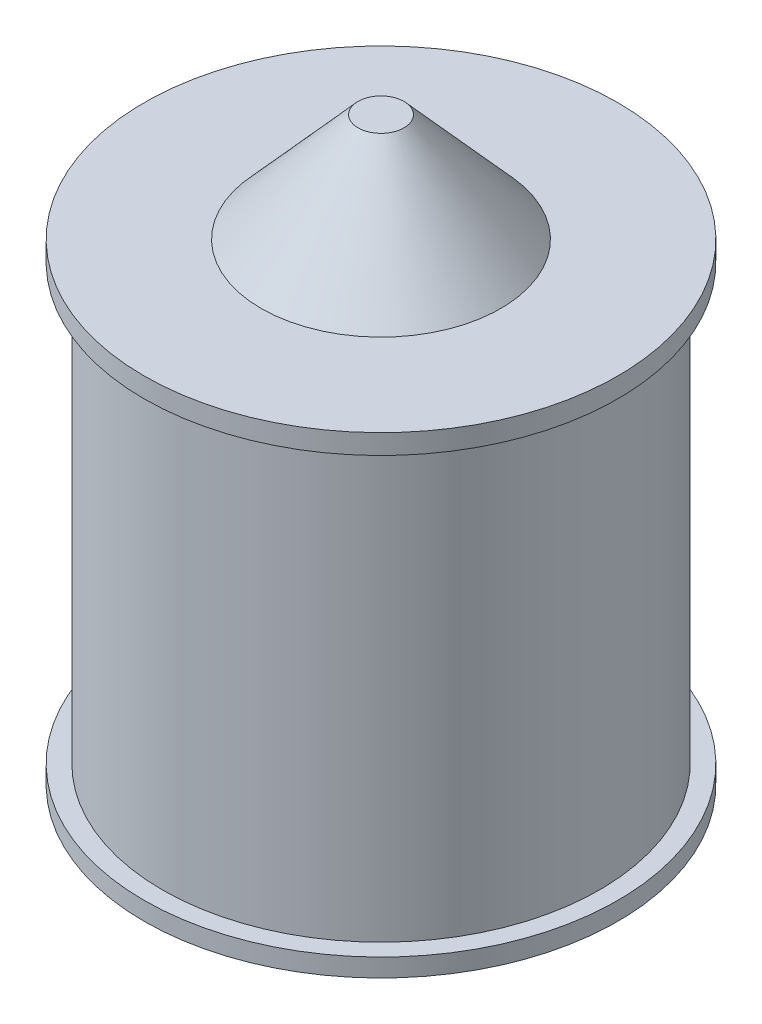
from build123d import *

# Parameters (mm, degrees)
CROQUIS3_W              = 2.5
CROQUIS3_H              = 93.200468797
CROQUIS3_H_2            = 93.221326365
SALIENTE_EXTRUIR1_DEPTH = 25
SALIENTE_EXTRUIR1_TAPER = 1


with BuildPart() as part:
    # Croquis1 → Revolución1 (revolve)
    with BuildSketch(Plane.XY):
        Polygon((0, 38.800633525), (0, -62.573128225), (50.821461866, -62.573128225), (50.821461866, -58.674137389), (46.92247103, -58.674137389), (46.92247103, 34.547188976), (50.821461866, 34.547188976), (50.821461866, 38.800633525), align=None)
    revolve(axis=Axis((0, 38.800633525, 0), (0, -1, 0)))

    # Croquis3 → Saliente-Extruir1 (add)
    with BuildSketch(Plane.XY):
        with Locations((-45.646866178, -12.07390299)):
            Rectangle(CROQUIS3_W, CROQUIS3_H)
        with Locations((-40.124494984, -12.063474207)):
            Rectangle(CROQUIS3_W, CROQUIS3_H_2)
    extrude(amount=-SALIENTE_EXTRUIR1_DEPTH, taper=SALIENTE_EXTRUIR1_TAPER)

    # Croquis6 → Revolución2 (revolve)
    with BuildSketch(Plane.XY):
        Polygon((0, 61.973262814), (0, 34.547188976), (-30.940786447, 34.547188976), (-30.940786447, 38.800633525), (-25.72291089, 38.800633525), (-4.924695463, 61.973262814), align=None)
    revolve(axis=Axis((0, 61.973262814, 0), (0, -1, 0)))


solid = part.part
